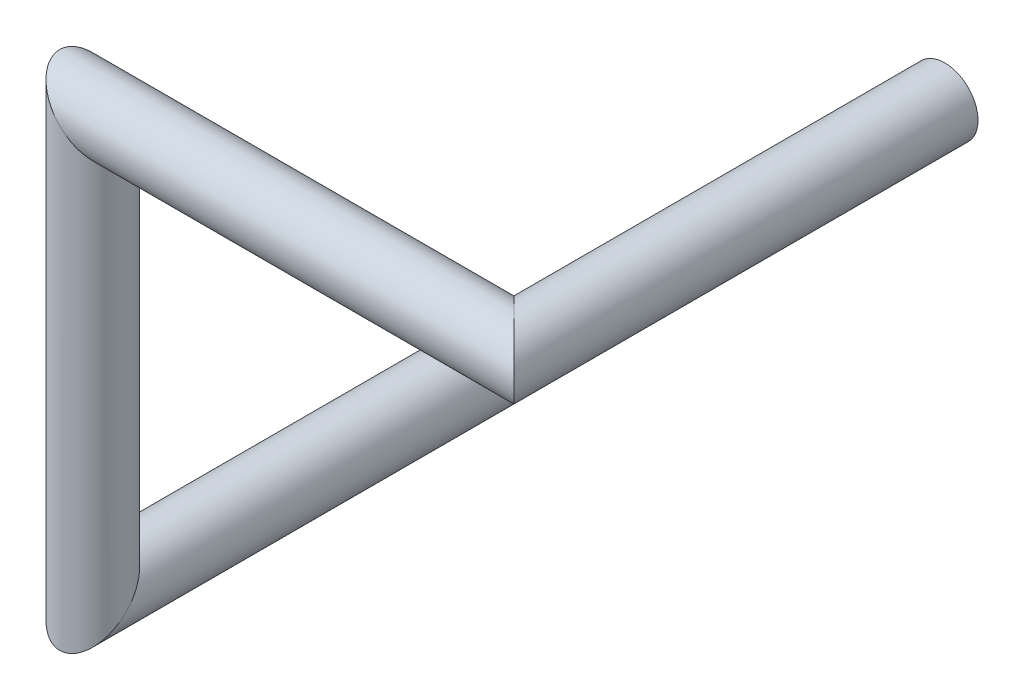
from build123d import *

# Parameters (mm, degrees)
SWEEP1_PROFILE_R = 0.2


with BuildPart() as part:
    # Sweep1: sweep along a curve in space
    with BuildLine() as sweep1_path:
        Line((0, 0, 0), (0, 0, 2.6))
        Line((0, 0, 2.6), (0, 2.54, 2.6))
        Line((0, 2.54, 2.6), (2.54, 2.54, 2.6))
        Line((2.54, 2.54, 2.6), (2.54, 2.54, 0))
    # Sweep1 profile (on start of the path) → Sweep1 (sweep)
    with BuildSketch(Plane.XY):
        Circle(SWEEP1_PROFILE_R)
    sweep(path=sweep1_path.line, transition=Transition.RIGHT)


solid = part.part
